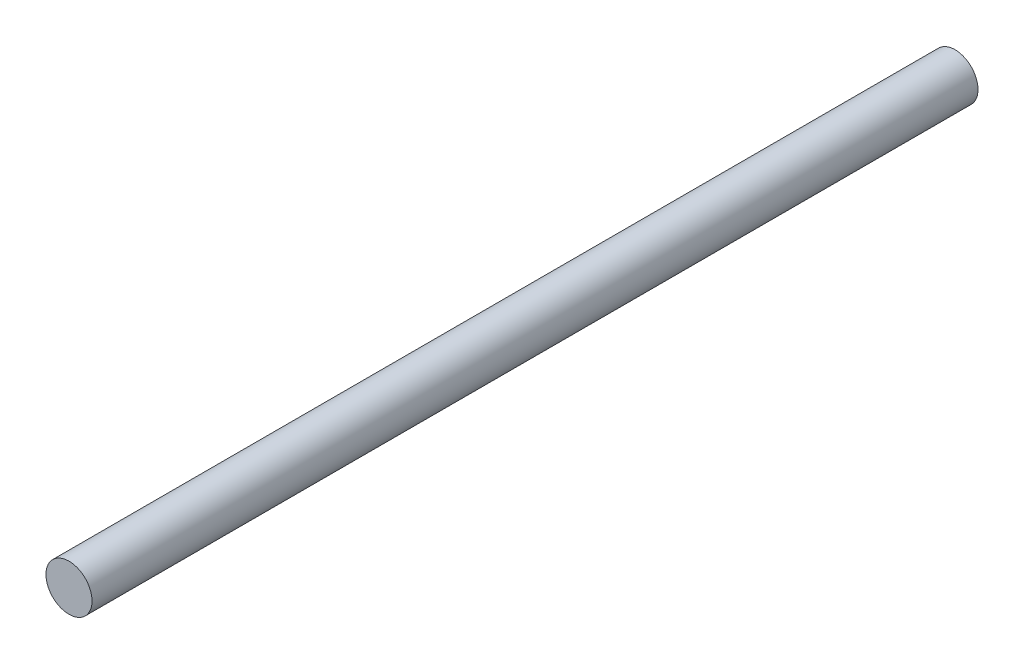
from build123d import *

# Parameters (mm, degrees)
ESBO_O1_R                = 3.9
RESSALTO_EXTRUS_O1_DEPTH = 150


with BuildPart() as part:
    # Esboço1 → Ressalto-extrusão1 (new body)
    with BuildSketch(Plane.XY):
        Circle(ESBO_O1_R)
    extrude(amount=RESSALTO_EXTRUS_O1_DEPTH)


solid = part.part
